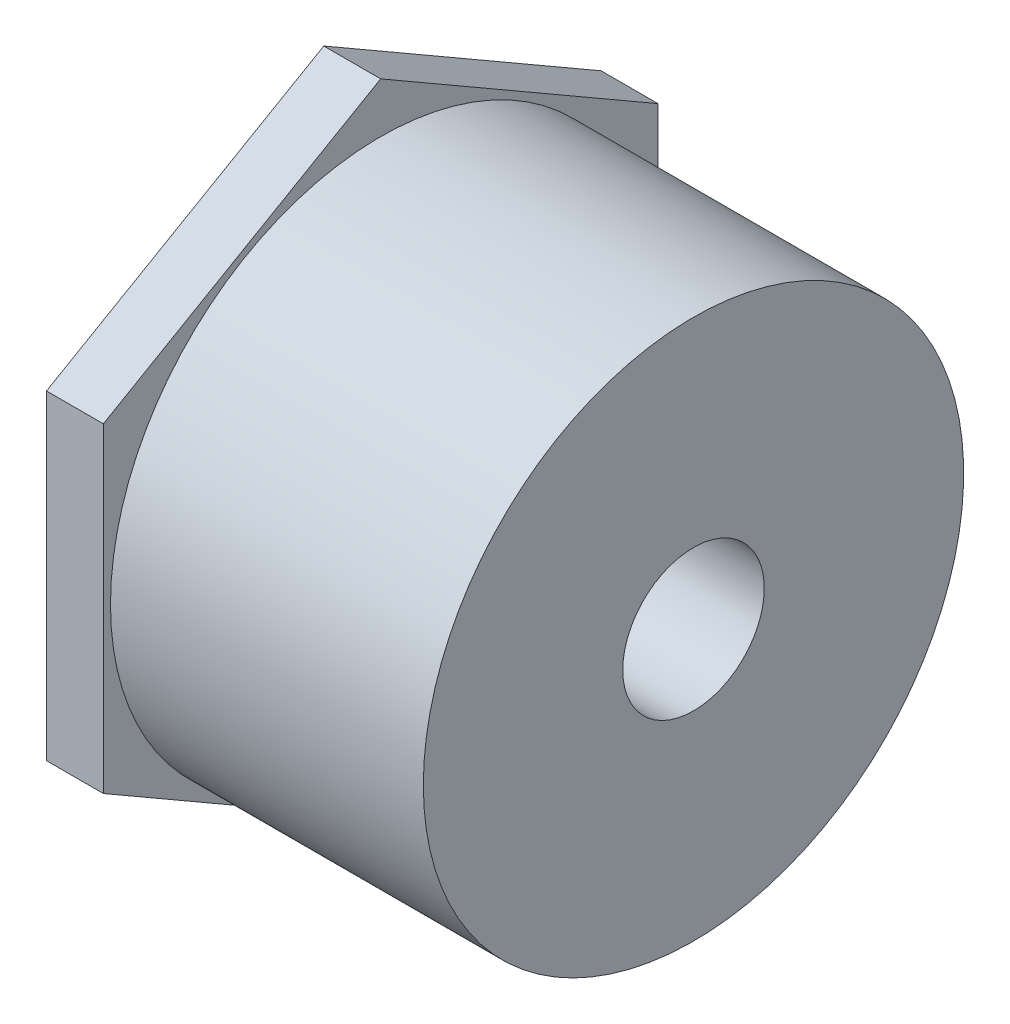
from build123d import *

# Parameters (mm, degrees)
SKETCH2_R           = 10.7696
BOSS_EXTRUDE1_DEPTH = 6.35


with BuildPart() as part:
    # Sketch1 → Revolve1 (revolve)
    with BuildSketch(Plane.XY):
        Polygon((-41.275, -30.1625), (0, -30.1625), (0, -7.8994), (-22.225, -7.8994), (-22.225, -10.6172), (-41.275, -10.7696), align=None)
    revolve(axis=Axis((-41.275, 0, 0), (1, 0, 0)))

    # Sketch2 → Boss-Extrude1 (add)
    with BuildSketch(Plane.ZY.offset(41.275)):
        Polygon((0, 35.745198541), (-30.95625, 17.872599271), (-30.95625, -17.872599271), (0, -35.745198541), (30.95625, -17.872599271), (30.95625, 17.872599271), align=None)
        Circle(SKETCH2_R, mode=Mode.SUBTRACT)
    extrude(amount=-BOSS_EXTRUDE1_DEPTH)


solid = part.part
